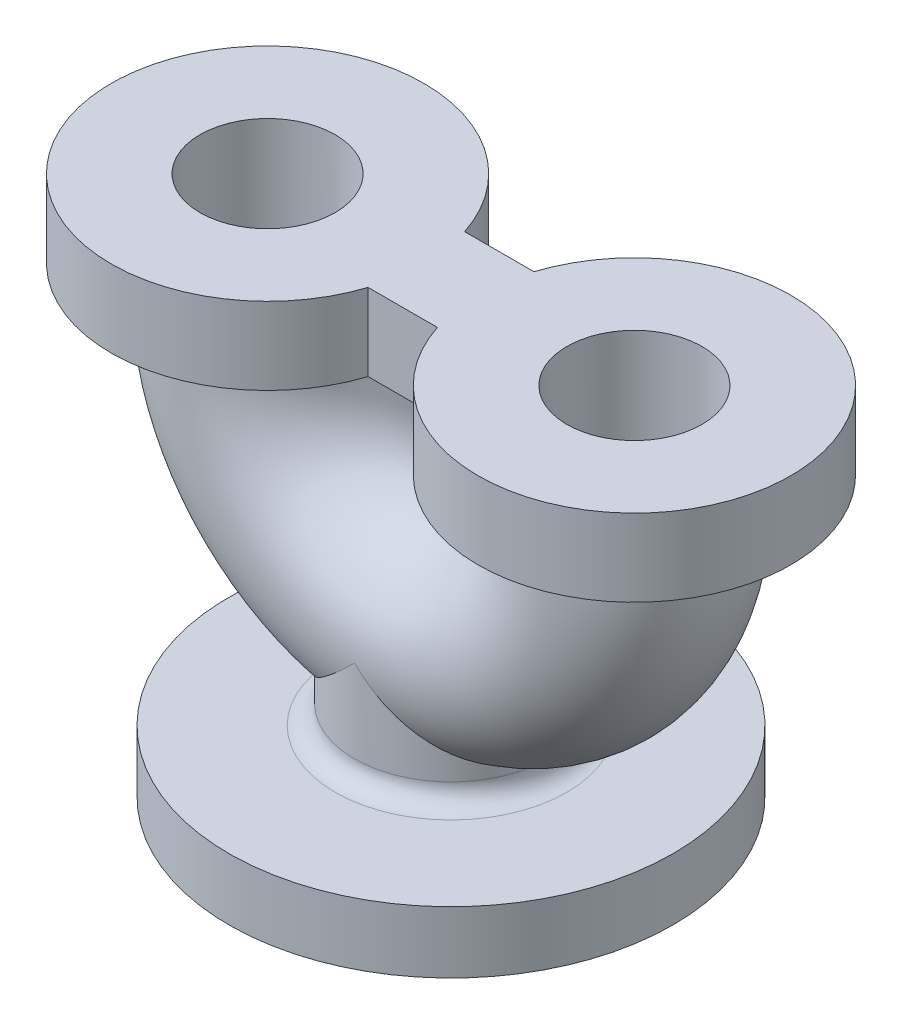
from build123d import *

# Parameters (mm, degrees)
SWEEP_THIN1_PROFILE_R         = 50
SWEEP_THIN1_PROFILE_R_2       = 35
SKETCH42_R                    = 57.5
SKETCH42_R_2                  = 35
BOSS_EXTRUDE1_DEPTH           = 12
SKETCH43_R                    = 81
SKETCH43_R_2                  = 35
BOSS_EXTRUDE2_DEPTH           = 40
BOSS_EXTRUDE3_DEPTH           = 40
BOSS_EXTRUDE4_REACH           = 280.455
SKETCH45_R                    = 50
SKETCH46_R                    = 115
BOSS_EXTRUDE5_DEPTH           = 32
CUT_EXTRUDE1_REACH            = 315.089
CUT_EXTRUDE1_END_MAJOR_RADIUS = 95
CUT_EXTRUDE1_END_MINOR_RADIUS = 35
SKETCH48_R                    = 35
FILLET1_R                     = 10


with BuildPart() as part:
    # Sweep-Thin1: sweep along a path in Sketch1
    with BuildLine(Plane.XY) as sweep_thin1_path:
        ThreePointArc((-95, 0), (0, -95), (95, 0))
    # Sweep-Thin1 profile (on start of the path) → Sweep-Thin1 (sweep)
    with BuildSketch(Plane(origin=(-95, 0, 0), x_dir=(-1, 0, 0), z_dir=(0, -1, 0))):
        Circle(SWEEP_THIN1_PROFILE_R)
        Circle(SWEEP_THIN1_PROFILE_R_2, mode=Mode.SUBTRACT)
    sweep(path=sweep_thin1_path.line)

    # Sketch42 → Boss-Extrude1 (add)
    with BuildSketch(Plane(origin=(0, 0, 0), x_dir=(1, 0, 0), z_dir=(0, 1, 0))):
        with Locations(Location((-95, 0, 0), (0, 0, 180))):
            Circle(SKETCH42_R)
        with Locations(Location((-95, 0, 0), (0, 0, 180))):
            Circle(SKETCH42_R_2, mode=Mode.SUBTRACT)
    boss_extrude1 = extrude(amount=BOSS_EXTRUDE1_DEPTH)

    # Sketch43 → Boss-Extrude2 (add)
    with BuildSketch(Plane(origin=(0, 12, 0), x_dir=(1, 0, 0), z_dir=(0, 1, 0))):
        with Locations(Location((-95, 0, 0), (0, 0, 180))):
            Circle(SKETCH43_R)
        with Locations(Location((-95, 0, 0), (0, 0, 180))):
            Circle(SKETCH43_R_2, mode=Mode.SUBTRACT)
    boss_extrude2 = extrude(amount=BOSS_EXTRUDE2_DEPTH)

    # Mirror1: Boss-Extrude1, Boss-Extrude2 across plane
    add(boss_extrude1.mirror(Plane(origin=(0, 0, 0), x_dir=(0, 0, 1), z_dir=(1, 0, 0))))
    add(boss_extrude2.mirror(Plane(origin=(0, 0, 0), x_dir=(0, 0, 1), z_dir=(1, 0, 0))))

    # Sketch44 → Boss-Extrude3 (add)
    with BuildSketch(Plane(origin=(0, 52, 0), x_dir=(1, 0, 0), z_dir=(0, 1, 0))):
        with BuildLine():
            Line((-17.954558863, 25), (17.954558863, 25))
            ThreePointArc((17.954558863, 25), (14, 0), (17.954558863, -25))
            Line((17.954558863, -25), (-17.954558863, -25))
            ThreePointArc((-17.954558863, -25), (-14, 0), (-17.954558863, 25))
        make_face()
    extrude(amount=-BOSS_EXTRUDE3_DEPTH)

    # Sketch45 → Boss-Extrude4 (add, up to next)
    with BuildSketch(Plane(origin=(0, -148, 0), x_dir=(1, 0, 0), z_dir=(0, 1, 0)), mode=Mode.PRIVATE) as boss_extrude4_sk1:
        with Locations(Location((0, 0, 0), (0, 0, 180))):
            Circle(SKETCH45_R)
    boss_extrude4_tool1 = extrude(boss_extrude4_sk1.sketch, amount=BOSS_EXTRUDE4_REACH, mode=Mode.PRIVATE) - part.part
    add(boss_extrude4_tool1.solids().sort_by_distance((0, -148, 0))[0])

    # Sketch46 → Boss-Extrude5 (add)
    with BuildSketch(Plane.XZ.offset(148)):
        Circle(SKETCH46_R)
    extrude(amount=BOSS_EXTRUDE5_DEPTH)

    # Cut-Extrude1: up to this torus (the profile starts outside it)
    cut_extrude1_end = Plane(origin=(0, 0, 0), z_dir=(0, 0, 1)) * Torus(CUT_EXTRUDE1_END_MAJOR_RADIUS, CUT_EXTRUDE1_END_MINOR_RADIUS, mode=Mode.PRIVATE)
    # Sketch48 → Cut-Extrude1 (cut, up to the surface)
    with BuildSketch(Plane.XZ.offset(180), mode=Mode.PRIVATE) as cut_extrude1_sk1:
        Circle(SKETCH48_R)
    cut_extrude1_tool1 = extrude(cut_extrude1_sk1.sketch, amount=-CUT_EXTRUDE1_REACH, mode=Mode.PRIVATE) - cut_extrude1_end
    add(cut_extrude1_tool1.solids().sort_by_distance((0, -180, 0))[0], mode=Mode.SUBTRACT)

    # Fillet1
    fillet1_edges = [part.edges().sort_by_distance(p)[0] for p in [
        (50, -148, 0),
    ]]
    fillet(fillet1_edges, radius=FILLET1_R)


solid = part.part
